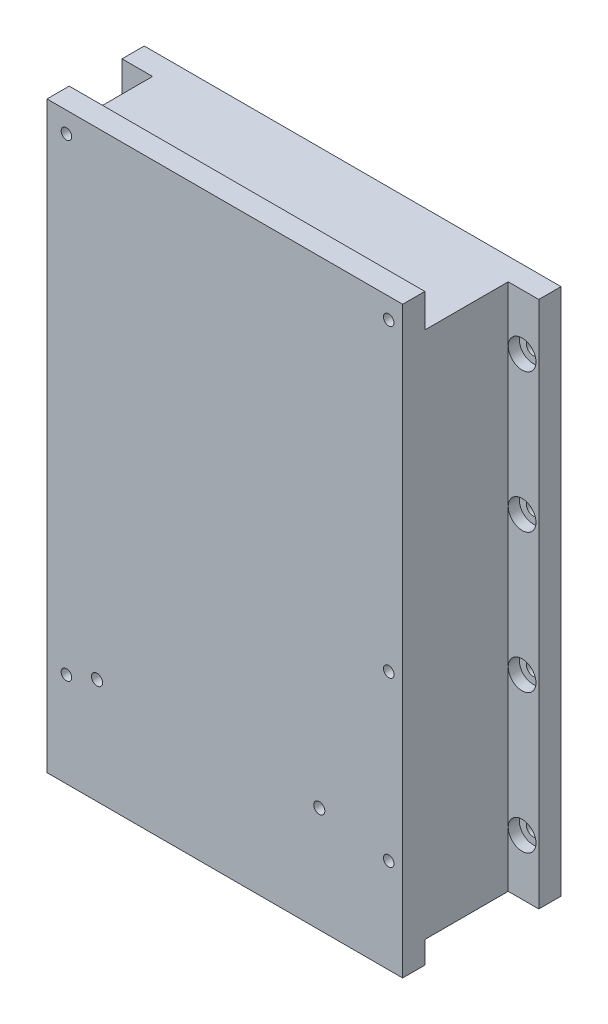
from build123d import *

# Parameters (mm, degrees)
SKETCH1_W           = 75
SKETCH1_H           = 95
BOSS_EXTRUDE1_DEPTH = 23
SKETCH3_W           = 55
SKETCH3_H           = 85
CUT_EXTRUDE2_DEPTH  = 19
SKETCH11_W          = 64
SKETCH11_H          = 105
BOSS_EXTRUDE2_DEPTH = 4
SKETCH5_W           = 5.5
SKETCH5_H           = 95
CUT_EXTRUDE4_DEPTH  = 19
SKETCH4_R           = 0.95
SKETCH4_R_2         = 1
CUT_EXTRUDE3_DEPTH  = 10
SKETCH6_R           = 1.25
CUT_EXTRUDE5_DEPTH  = 5
CUT_EXTRUDE6_REACH  = 11
SKETCH7_W           = 50
SKETCH7_H           = 8
SKETCH10_R          = 2.5
CUT_EXTRUDE9_DEPTH  = 2


with BuildPart() as part:
    # Sketch1 → Boss-Extrude1 (new body)
    with BuildSketch(Plane.XY):
        with Locations((37.5, 47.5)):
            Rectangle(SKETCH1_W, SKETCH1_H)
    extrude(amount=BOSS_EXTRUDE1_DEPTH)

    # Sketch3 → Cut-Extrude2 (cut)
    with BuildSketch(Plane(origin=(0, 0, 0), x_dir=(-1, 0, 0), z_dir=(0, 0, -1))):
        with Locations((-37.5, 47.5)):
            Rectangle(SKETCH3_W, SKETCH3_H)
    extrude(amount=-CUT_EXTRUDE2_DEPTH, mode=Mode.SUBTRACT)

    # Sketch11 → Boss-Extrude2 (add)
    with BuildSketch(Plane(origin=(0, 0, 19), x_dir=(-1, 0, 0), z_dir=(0, 0, -1))):
        with Locations((-37.5, 48.5)):
            Rectangle(SKETCH11_W, SKETCH11_H)
    extrude(amount=-BOSS_EXTRUDE2_DEPTH)

    # Sketch5 → Cut-Extrude4 (cut)
    with BuildSketch(Plane.XY.offset(23)):
        with Locations((72.25, 47.5)):
            Rectangle(SKETCH5_W, SKETCH5_H)
        with Locations((2.75, 47.5)):
            Rectangle(SKETCH5_W, SKETCH5_H)
    extrude(amount=-CUT_EXTRUDE4_DEPTH, mode=Mode.SUBTRACT)

    # Sketch4 → Cut-Extrude3 (cut)
    with BuildSketch(Plane(origin=(0, 0, 23), x_dir=(-1, 0, 0), z_dir=(0, 0, -1))):
        with Locations((-9, 97.31)):
            Circle(SKETCH4_R)
        with Locations((-67, 97.31)):
            Circle(SKETCH4_R)
        with Locations((-67, 42.51)):
            Circle(SKETCH4_R)
        with Locations((-67, 13.01)):
            Circle(SKETCH4_R)
        with Locations((-9, 13.01)):
            Circle(SKETCH4_R)
        with Locations((-14.5, 15)):
            Circle(SKETCH4_R_2)
        with Locations((-54.5, 15)):
            Circle(SKETCH4_R_2)
    extrude(amount=CUT_EXTRUDE3_DEPTH, mode=Mode.SUBTRACT)

    # Sketch6 → Cut-Extrude5 (cut, through all)
    with BuildSketch(Plane.XY.offset(4)):
        with Locations((72, 10)):
            Circle(SKETCH6_R)
        with Locations((3, 10)):
            Circle(SKETCH6_R)
        with Locations((72, 35)):
            Circle(SKETCH6_R)
        with Locations((3, 35)):
            Circle(SKETCH6_R)
        with Locations((72, 60)):
            Circle(SKETCH6_R)
        with Locations((3, 60)):
            Circle(SKETCH6_R)
        with Locations((72, 85)):
            Circle(SKETCH6_R)
        with Locations((3, 85)):
            Circle(SKETCH6_R)
    extrude(amount=-CUT_EXTRUDE5_DEPTH, mode=Mode.SUBTRACT)

    # Sketch7 → Cut-Extrude6 (cut, up to next)
    with BuildSketch(Plane(origin=(0, 5, 0), x_dir=(1, 0, 0), z_dir=(0, 1, 0)), mode=Mode.PRIVATE) as cut_extrude6_sk1:
        with Locations((35, -15)):
            Rectangle(SKETCH7_W, SKETCH7_H)
    cut_extrude6_tool1 = extrude(cut_extrude6_sk1.sketch, amount=-CUT_EXTRUDE6_REACH, mode=Mode.PRIVATE) & part.part
    add(cut_extrude6_tool1.solids().sort_by_distance((35, 5, 15))[0], mode=Mode.SUBTRACT)

    # Sketch10 → Cut-Extrude9 (cut)
    with BuildSketch(Plane.XY.offset(4)):
        with Locations((72, 10)):
            Circle(SKETCH10_R)
        with Locations((72, 35)):
            Circle(SKETCH10_R)
        with Locations((72, 60)):
            Circle(SKETCH10_R)
        with Locations((72, 85)):
            Circle(SKETCH10_R)
        with Locations((3, 10)):
            Circle(SKETCH10_R)
        with Locations((3, 35)):
            Circle(SKETCH10_R)
        with Locations((3, 60)):
            Circle(SKETCH10_R)
        with Locations((3, 85)):
            Circle(SKETCH10_R)
    extrude(amount=-CUT_EXTRUDE9_DEPTH, mode=Mode.SUBTRACT)


solid = part.part
